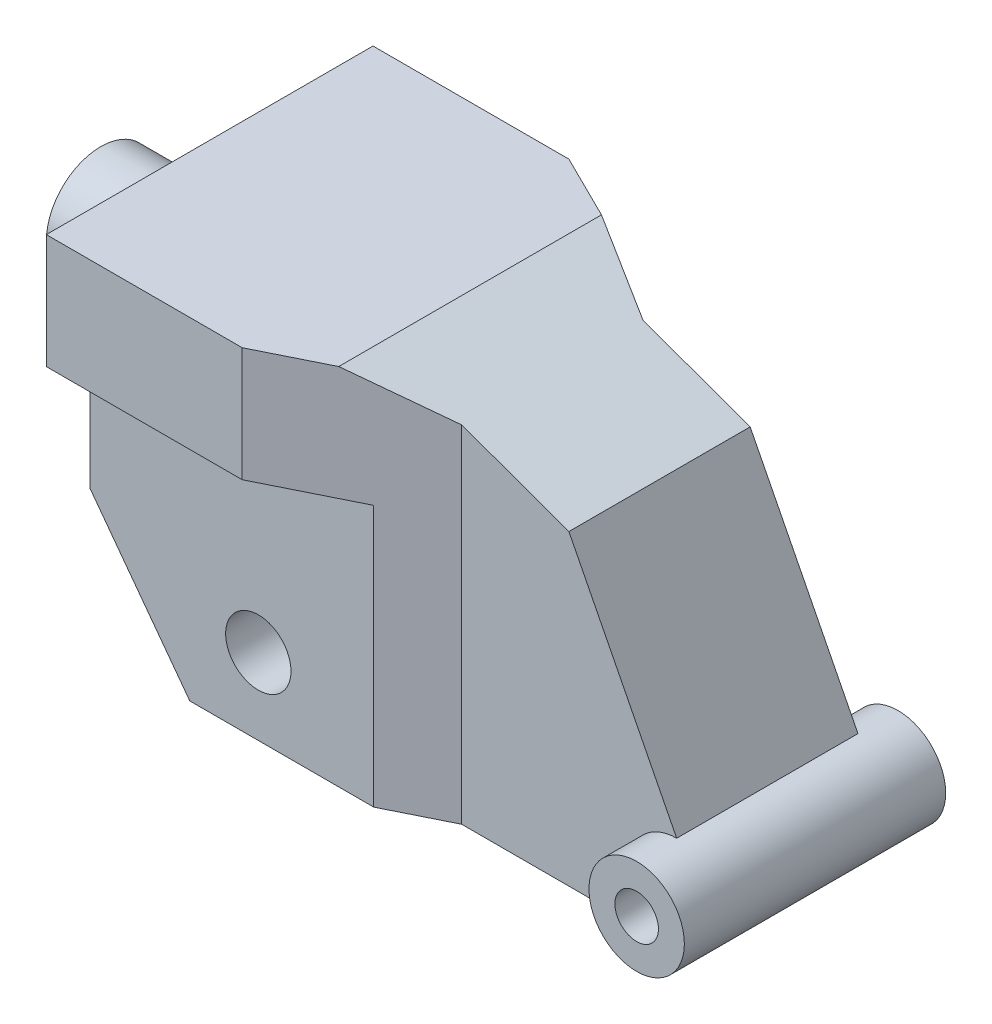
from build123d import *

# Parameters (mm, degrees)
EXTRUDE_1_DEPTH          = 75
SKETCH_2_W               = 185.8
SKETCH_2_H               = 57.3
CUT_EXTRUDE_2_DEPTH      = 120
CUT_EXTRUDE_3_DEPTH      = 400
SKETCH_5_R               = 21.9
EXTRUDE_2_DEPTH          = 60
SKETCH_6_R               = 10
CUT_EXTRUDE_4_DEPTH      = 200
SKETCH_8_R               = 15
CUT_EXTRUDE_5_DEPTH      = 21
CUT_EXTRUDE_5_DEPTH_BACK = 131
SKETCH_9_R               = 25
EXTRUDE_3_DEPTH          = 50


with BuildPart() as part:
    # 草图1 → 凸台-拉伸1 (new body, symmetric)
    with BuildSketch(Plane.XY):
        Polygon((-119.6, 172.501416068), (0, 172.501416068), (86.979350222, 141.023763122), (136.480359145, 43.8), (136.480359145, 0), (-73.719640855, 0), (-119.6, 61.701416068), align=None)
    extrude(amount=EXTRUDE_1_DEPTH, both=True)

    # 草图2 → 切除-拉伸2 (cut)
    with BuildSketch(Plane(origin=(0, 0, 0), x_dir=(1, 0, 0), z_dir=(0, 1, 0))):
        with Locations((-51.7, 83.65)):
            Rectangle(SKETCH_2_W, SKETCH_2_H)
        with Locations((-51.7, -83.65)):
            Rectangle(SKETCH_2_W, SKETCH_2_H)
    extrude(amount=CUT_EXTRUDE_2_DEPTH, mode=Mode.SUBTRACT)

    # 草图3 → 切除-拉伸3 (cut)
    with BuildSketch(Plane(origin=(0, 172.501416068, 0), x_dir=(1, 0, 0), z_dir=(0, 1, 0))):
        Polygon((-64.837283081, 92.42032951), (245.362716919, 92.42032951), (245.362716919, 41.62032951), (37.776604868, 41.62032951), align=None)
        Polygon((37.776604868, -41.62032951), (-64.837283081, -92.42032951), (245.362716919, -92.42032951), (245.362716919, -41.62032951), align=None)
    extrude(amount=-CUT_EXTRUDE_3_DEPTH, mode=Mode.SUBTRACT)

    # 草图5 → 凸台-拉伸2 (add, symmetric)
    with BuildSketch(Plane.XY):
        with Locations((136.480359145, 21.9)):
            Circle(SKETCH_5_R)
    extrude(amount=EXTRUDE_2_DEPTH, both=True)

    # 草图6 → 切除-拉伸4 (cut)
    with BuildSketch(Plane.XY.offset(60)):
        with Locations((136.480359145, 21.9)):
            Circle(SKETCH_6_R)
    extrude(amount=-CUT_EXTRUDE_4_DEPTH, mode=Mode.SUBTRACT)

    # 草图8 → 切除-拉伸5 (cut, two sides)
    with BuildSketch(Plane.XY.offset(55)) as cut_extrude_5_sk:
        with Locations((-42.249773251, 35)):
            Circle(SKETCH_8_R)
    extrude(amount=CUT_EXTRUDE_5_DEPTH, mode=Mode.SUBTRACT)
    extrude(cut_extrude_5_sk.sketch, amount=-CUT_EXTRUDE_5_DEPTH_BACK, mode=Mode.SUBTRACT)

    # 草图9 → 凸台-拉伸3 (add)
    with BuildSketch(Plane.ZY.offset(119.6)):
        with Locations((0, 120)):
            Circle(SKETCH_9_R)
    extrude(amount=EXTRUDE_3_DEPTH)


solid = part.part
